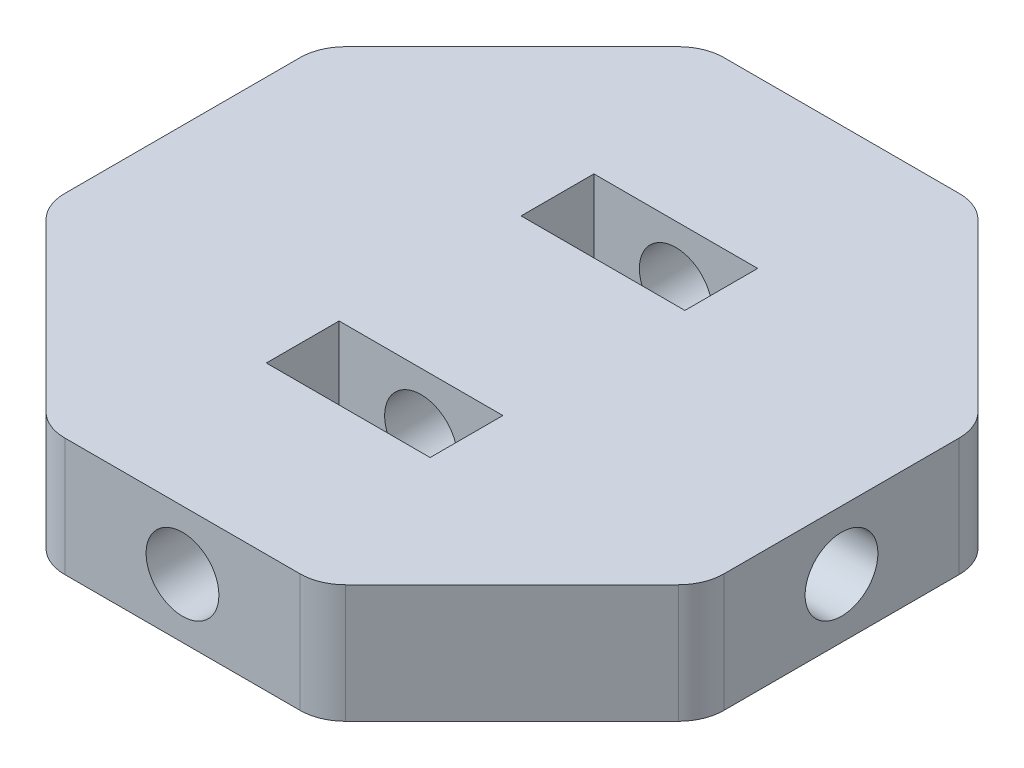
from build123d import *

# Parameters (mm, degrees)
EXTRUDE2_DEPTH = 13
EXTRUDE3_REACH = 74.426
SKETCH2_R      = 4
SKETCH3_R      = 4
EXTRUDE4_DEPTH = 73.426406871
SKETCH4_W      = 18
SKETCH4_H      = 8
EXTRUDE5_DEPTH = 13
FILLET1_R      = 5


with BuildPart() as part:
    # Sketch1 → Extrude2 (new body)
    with BuildSketch(Plane(origin=(0, 0, 0), x_dir=(1, 0, 0), z_dir=(0, 1, 0))):
        Polygon((15, -36.213203436), (36.213203436, -15), (36.213203436, 15), (15, 36.213203436), (-15, 36.213203436), (-36.213203436, 15), (-36.213203436, -15), (-15, -36.213203436), align=None)
    extrude(amount=EXTRUDE2_DEPTH)

    # Sketch2 → Extrude3 (cut, up to next)
    with BuildSketch(Plane(origin=(36.213203436, 0, 0), x_dir=(0, 0, -1), z_dir=(1, 0, 0)), mode=Mode.PRIVATE) as extrude3_sk1:
        with Locations((0, 6.5)):
            Circle(SKETCH2_R)
    extrude3_tool1 = extrude(extrude3_sk1.sketch, amount=-EXTRUDE3_REACH, mode=Mode.PRIVATE) & part.part
    add(extrude3_tool1.solids().sort_by_distance((36.213203, 6.5, 0))[0], mode=Mode.SUBTRACT)

    # Sketch3 → Extrude4 (cut, through all)
    with BuildSketch(Plane.XY.offset(36.213203436)):
        with Locations((0, 6.5)):
            Circle(SKETCH3_R)
    extrude(amount=-EXTRUDE4_DEPTH, mode=Mode.SUBTRACT)

    # Sketch4 → Extrude5 (cut)
    with BuildSketch(Plane(origin=(0, 13, 0), x_dir=(1, 0, 0), z_dir=(0, 1, 0))):
        with Locations((0, -14)):
            Rectangle(SKETCH4_W, SKETCH4_H)
        with Locations((0, 14)):
            Rectangle(SKETCH4_W, SKETCH4_H)
    extrude(amount=-EXTRUDE5_DEPTH, mode=Mode.SUBTRACT)

    # Fillet1
    fillet1_edges = [part.edges().sort_by_distance(p)[0] for p in [
        (36.213203436, 6.5, 15),
        (15, 6.5, 36.213203436),
        (-15, 6.5, 36.213203436),
        (-36.213203436, 6.5, 15),
        (-36.213203436, 6.5, -15),
        (-15, 6.5, -36.213203436),
        (15, 6.5, -36.213203436),
        (36.213203436, 6.5, -15),
    ]]
    fillet(fillet1_edges, radius=FILLET1_R)


solid = part.part
